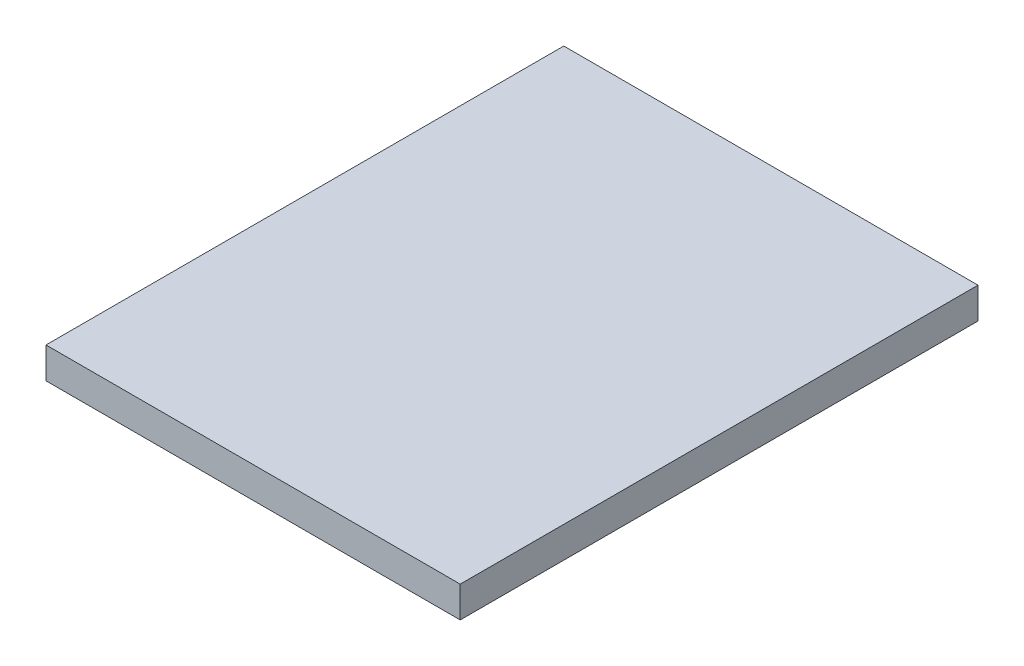
from build123d import *

# Parameters (mm, degrees)
SKETCH2_W           = 80
SKETCH2_H           = 100
BOSS_EXTRUDE1_DEPTH = 6
SCALE1_SCALE        = 7.5


with BuildPart() as part:
    # Sketch2 → Boss-Extrude1 (new body)
    with BuildSketch(Plane(origin=(0, 0, 0), x_dir=(1, 0, 0), z_dir=(0, 1, 0))):
        with Locations((40, 50)):
            Rectangle(SKETCH2_W, SKETCH2_H)
    extrude(amount=BOSS_EXTRUDE1_DEPTH)


with BuildPart() as part_1:
    # Scale1: scaled about (40, 3, -50)
    add(part.part.scale(SCALE1_SCALE).moved(Location((-260, -19.5, 325))))


solid = part_1.part
